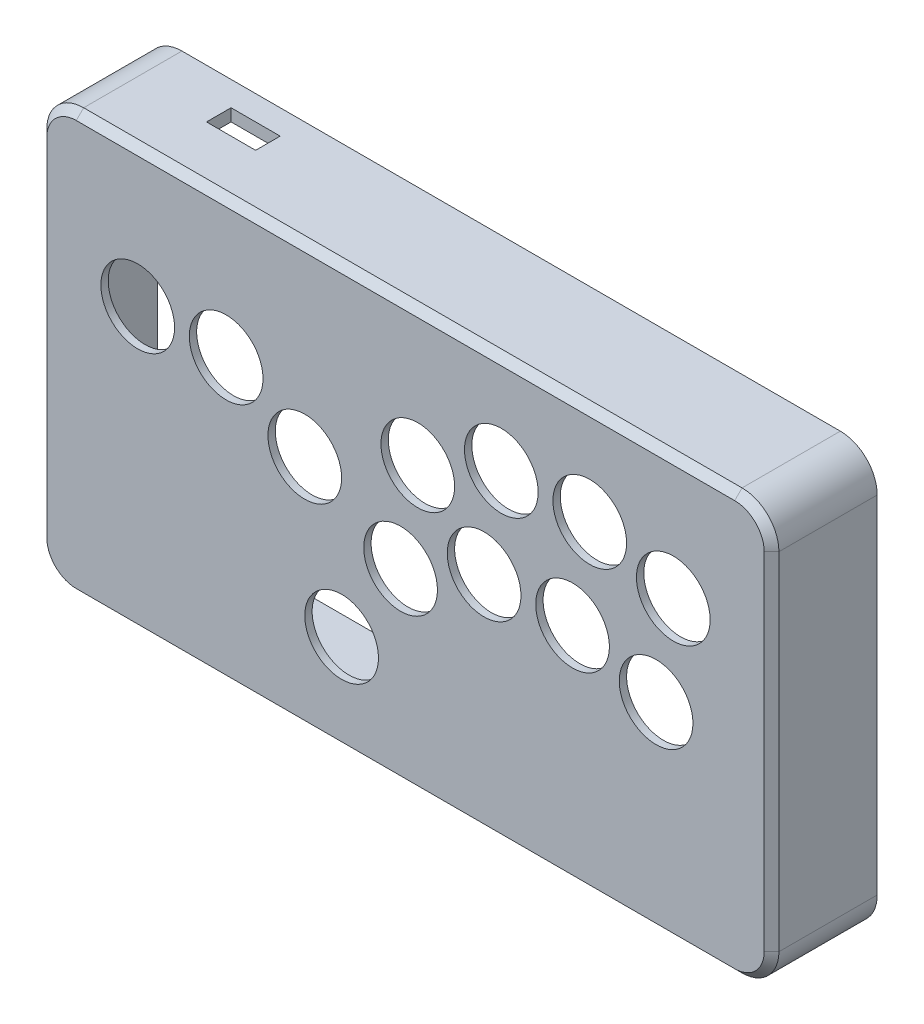
from build123d import *

# Parameters (mm, degrees)
SKETCH1_R           = 15
BOSS_EXTRUDE1_DEPTH = 3
BOSS_EXTRUDE2_DEPTH = 40
CHAMFER1_SIZE       = 3
SKETCH4_R           = 10
BOSS_EXTRUDE3_DEPTH = 35
SKETCH6_W           = 20
SKETCH6_H           = 10
CUT_EXTRUDE1_DEPTH  = 5
SKETCH8_R           = 1.5
CUT_EXTRUDE3_DEPTH  = 4


with BuildPart() as part:
    # Sketch1 → Boss-Extrude1 (new body)
    with BuildSketch(Plane.XY):
        with BuildLine():
            Line((-123, 116), (-123, -25))
            ThreePointArc((-123, -25), (-118.606601718, -35.606601718), (-108, -40))
            Line((-108, -40), (160, -40))
            ThreePointArc((160, -40), (170.606601718, -35.606601718), (175, -25))
            Line((175, -25), (175, 116))
            ThreePointArc((175, 116), (170.606601718, 126.606601718), (160, 131))
            Line((160, 131), (-108, 131))
            ThreePointArc((-108, 131), (-118.606601718, 126.606601718), (-123, 116))
        make_face()
        Circle(SKETCH1_R, mode=Mode.SUBTRACT)
        with Locations((-47, 75)):
            Circle(SKETCH1_R, mode=Mode.SUBTRACT)
        with Locations((-15, 56)):
            Circle(SKETCH1_R, mode=Mode.SUBTRACT)
        with Locations((-83, 75)):
            Circle(SKETCH1_R, mode=Mode.SUBTRACT)
        with Locations((31, 76)):
            Circle(SKETCH1_R, mode=Mode.SUBTRACT)
        with Locations((65, 91)):
            Circle(SKETCH1_R, mode=Mode.SUBTRACT)
        with Locations((101, 91)):
            Circle(SKETCH1_R, mode=Mode.SUBTRACT)
        with Locations((24, 36)):
            Circle(SKETCH1_R, mode=Mode.SUBTRACT)
        with Locations((58, 51)):
            Circle(SKETCH1_R, mode=Mode.SUBTRACT)
        with Locations((94, 51)):
            Circle(SKETCH1_R, mode=Mode.SUBTRACT)
        with Locations((135, 81)):
            Circle(SKETCH1_R, mode=Mode.SUBTRACT)
        with Locations((128, 41)):
            Circle(SKETCH1_R, mode=Mode.SUBTRACT)
    extrude(amount=-BOSS_EXTRUDE1_DEPTH)

    # Sketch2 → Boss-Extrude2 (add)
    with BuildSketch(Plane(origin=(0, 0, -3), x_dir=(-1, 0, 0), z_dir=(0, 0, -1))):
        with BuildLine():
            Line((123, -25), (123, 116))
            ThreePointArc((123, 116), (118.606601718, 126.606601718), (108, 131))
            Line((108, 131), (-160, 131))
            ThreePointArc((-160, 131), (-170.606601718, 126.606601718), (-175, 116))
            Line((-175, 116), (-175, -25))
            ThreePointArc((-175, -25), (-170.606601718, -35.606601718), (-160, -40))
            Line((-160, -40), (108, -40))
            ThreePointArc((108, -40), (118.606601718, -35.606601718), (123, -25))
        make_face()
        with BuildLine():
            Line((118, -25), (118, 116))
            ThreePointArc((118, 116), (115.071067812, 123.071067812), (108, 126))
            Line((108, 126), (-160, 126))
            ThreePointArc((-160, 126), (-167.071067812, 123.071067812), (-170, 116))
            Line((-170, 116), (-170, -25))
            ThreePointArc((-170, -25), (-167.071067812, -32.071067812), (-160, -35))
            Line((-160, -35), (108, -35))
            ThreePointArc((108, -35), (115.071067812, -32.071067812), (118, -25))
        make_face(mode=Mode.SUBTRACT)
    extrude(amount=BOSS_EXTRUDE2_DEPTH)

    # Chamfer1
    chamfer1_edges = [part.edges().sort_by_distance(p)[0] for p in [
        (26, 131, 0),
        (170.606601718, 126.606601718, 0),
        (175, 45.5, 0),
        (170.606601718, -35.606601718, 0),
        (26, -40, 0),
        (-118.606601718, -35.606601718, 0),
        (-123, 45.5, 0),
        (-118.606601718, 126.606601718, 0),
    ]]
    chamfer(chamfer1_edges, length=CHAMFER1_SIZE)

    # Sketch4 → Boss-Extrude3 (add)
    with BuildSketch(Plane(origin=(0, 0, -3), x_dir=(-1, 0, 0), z_dir=(0, 0, -1))):
        with Locations((-160, 116)):
            Circle(SKETCH4_R)
        with Locations((108, 116)):
            Circle(SKETCH4_R)
        with Locations((-160, -25)):
            Circle(SKETCH4_R)
        with Locations((108, -25)):
            Circle(SKETCH4_R)
    extrude(amount=BOSS_EXTRUDE3_DEPTH)

    # Sketch6 → Cut-Extrude1 (cut)
    with BuildSketch(Plane(origin=(0, 131, 0), x_dir=(1, 0, 0), z_dir=(0, 1, 0))):
        with Locations((-68, 28)):
            Rectangle(SKETCH6_W, SKETCH6_H)
    extrude(amount=-CUT_EXTRUDE1_DEPTH, mode=Mode.SUBTRACT)

    # Sketch8 → Cut-Extrude3 (cut)
    with BuildSketch(Plane(origin=(0, 0, -38), x_dir=(-1, 0, 0), z_dir=(0, 0, -1))):
        with Locations((-160, 116)):
            Circle(SKETCH8_R)
        with Locations((108, 116)):
            Circle(SKETCH8_R)
        with Locations((-160, -25)):
            Circle(SKETCH8_R)
        with Locations((108, -25)):
            Circle(SKETCH8_R)
    extrude(amount=-CUT_EXTRUDE3_DEPTH, mode=Mode.SUBTRACT)


solid = part.part
